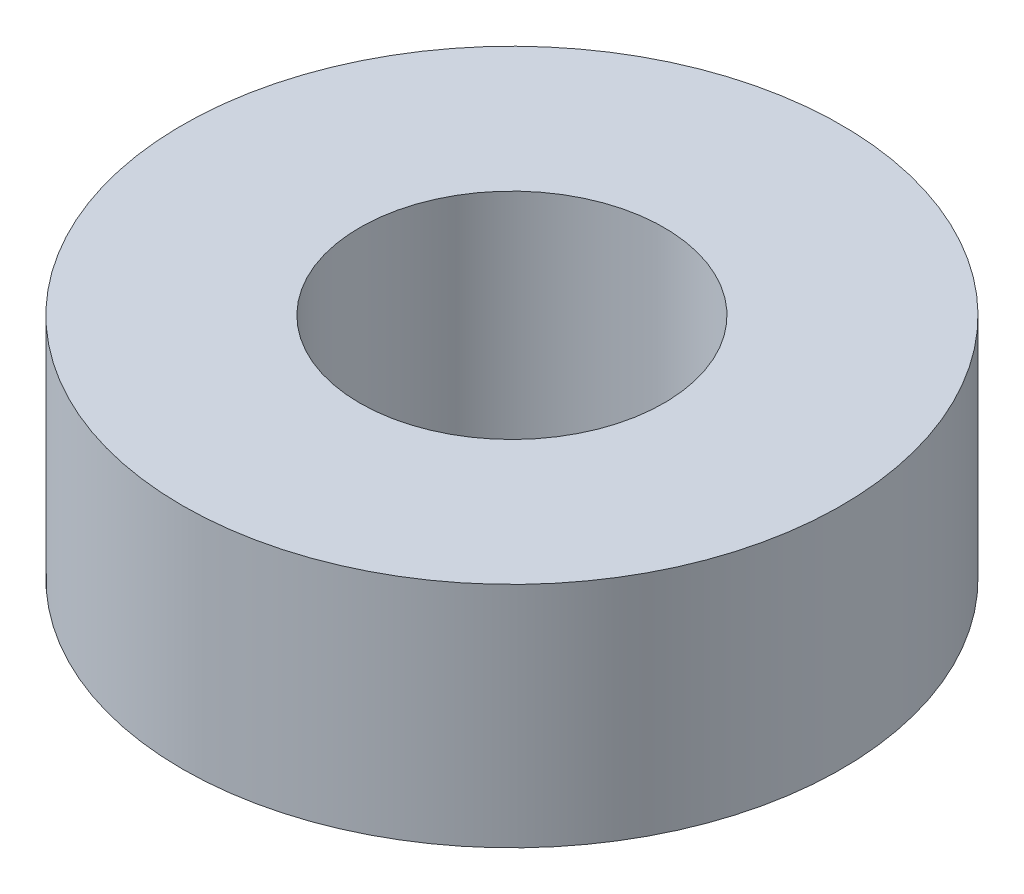
from build123d import *

# Parameters (mm, degrees)
SKETCH1_R           = 6.5
SKETCH1_R_2         = 3
BOSS_EXTRUDE2_DEPTH = 4.5


with BuildPart() as part:
    # Sketch1 → Boss-Extrude2 (new body)
    with BuildSketch(Plane(origin=(0, 0, 0), x_dir=(1, 0, 0), z_dir=(0, 1, 0))):
        Circle(SKETCH1_R)
        Circle(SKETCH1_R_2, mode=Mode.SUBTRACT)
    extrude(amount=BOSS_EXTRUDE2_DEPTH)


solid = part.part
